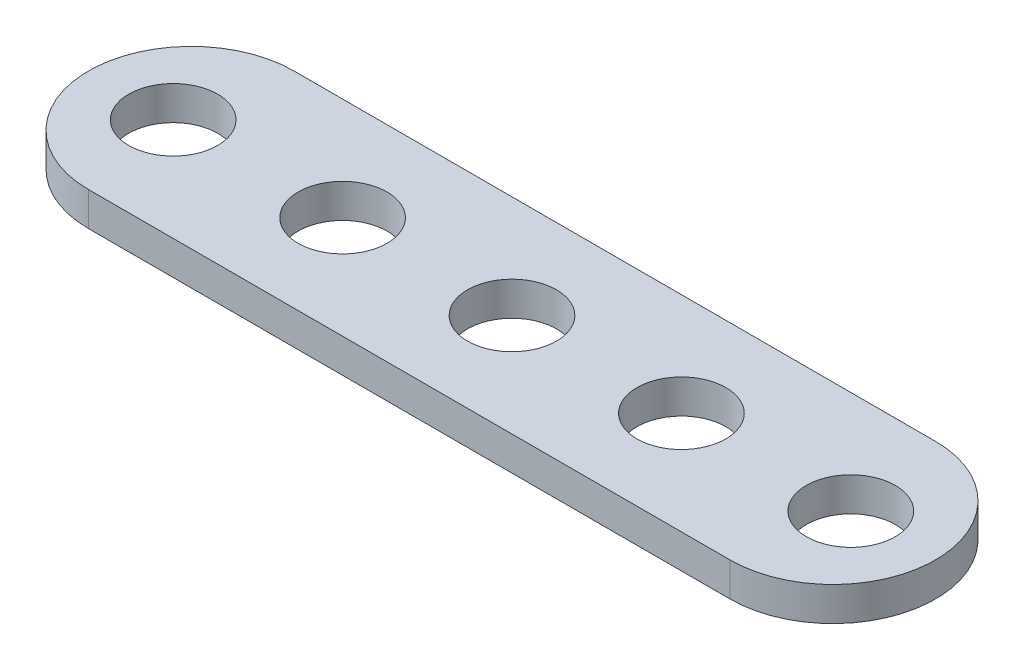
from build123d import *

# Parameters (mm, degrees)
BOSS_EXTRUDE1_DEPTH = 1.6
SKETCH2_R           = 2.1
CUT_EXTRUDE1_DEPTH  = 2.6
LPATTERN1_COUNT     = 5
LPATTERN1_PITCH     = 8


with BuildPart() as part:
    # Sketch1 → Boss-Extrude1 (new body)
    with BuildSketch(Plane(origin=(0, 0, 0), x_dir=(1, 0, 0), z_dir=(0, 1, 0))):
        with BuildLine():
            Line((4.85, 4.85), (35.15, 4.85))
            ThreePointArc((35.15, 4.85), (40, 0), (35.15, -4.85))
            Line((35.15, -4.85), (4.85, -4.85))
            ThreePointArc((4.85, -4.85), (0, 0), (4.85, 4.85))
        make_face()
    extrude(amount=BOSS_EXTRUDE1_DEPTH)

    # Sketch2 → Cut-Extrude1 (cut, through all)
    with BuildSketch(Plane(origin=(0, 1.6, 0), x_dir=(1, 0, 0), z_dir=(0, 1, 0))):
        with Locations((4, 0)):
            Circle(SKETCH2_R)
    cut_extrude1 = extrude(amount=-CUT_EXTRUDE1_DEPTH, mode=Mode.SUBTRACT)

    # LPattern1: Cut-Extrude1 ×5
    with Locations(*[(i * LPATTERN1_PITCH, 0, 0) for i in range(1, LPATTERN1_COUNT)]):
        add(cut_extrude1, mode=Mode.SUBTRACT)


solid = part.part
